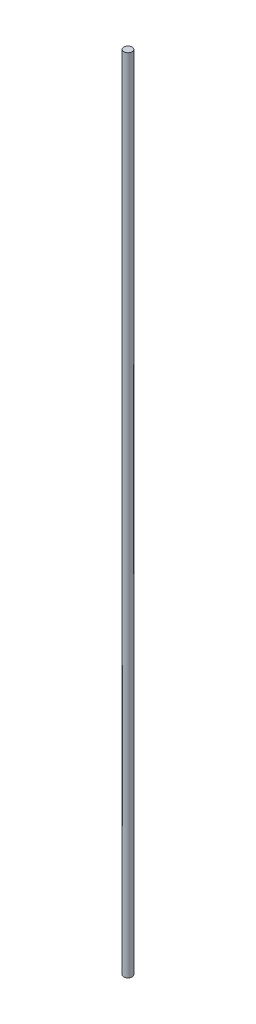
from build123d import *

# Parameters (mm, degrees)
ESBO_O1_R                = 3.97
RESSALTO_EXTRUS_O1_DEPTH = 384


with BuildPart() as part:
    # Esboço1 → Ressalto-extrusão1 (new body, symmetric)
    with BuildSketch(Plane(origin=(0, 0, 0), x_dir=(1, 0, 0), z_dir=(0, 1, 0))):
        Circle(ESBO_O1_R)
    extrude(amount=RESSALTO_EXTRUS_O1_DEPTH, both=True)


solid = part.part
